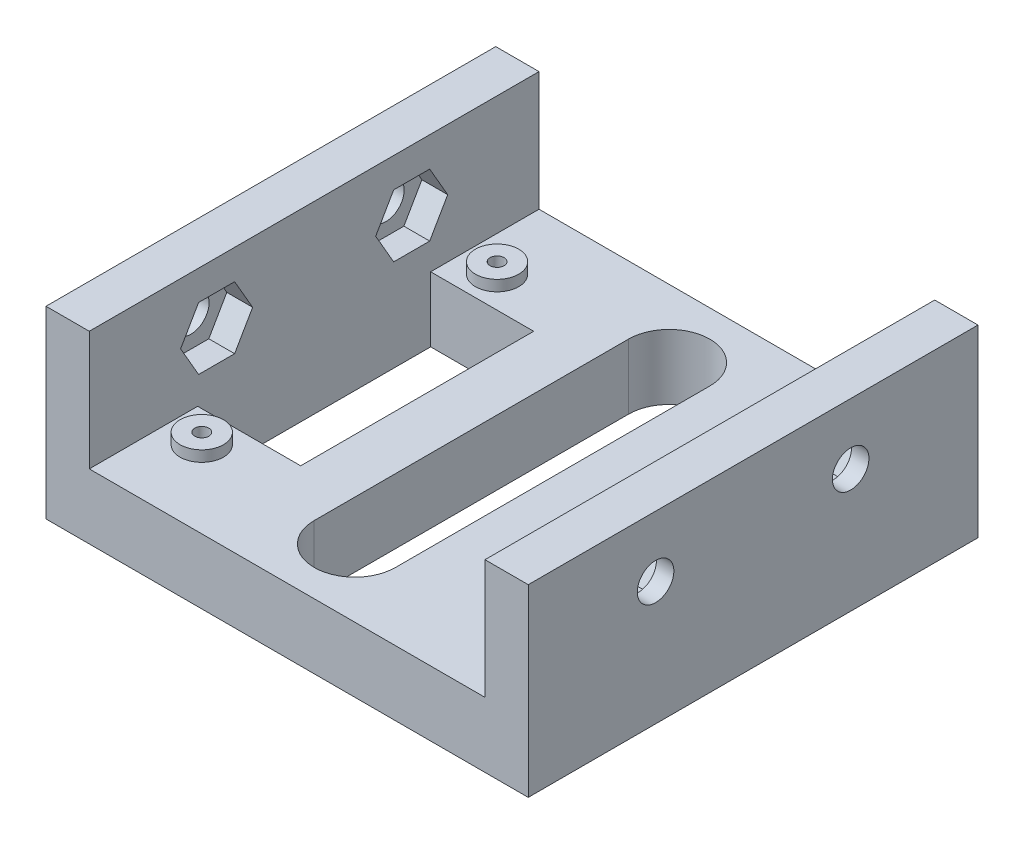
from build123d import *

# Parameters (mm, degrees)
SKETCH1_W                   = 89
SKETCH1_H                   = 83
SKETCH1_R                   = 1.3
MAIN_BODY_DEPTH             = 14
SKETCH2_W                   = 73.025
SKETCH2_H                   = 83
SKETCH2_R                   = 4
SCREW_RISER_DEPTH           = 2
SKETCH4_W                   = 7.9875
SKETCH4_H                   = 83
TOPPER_SUPPORT_DEPTH        = 20
MOUNT_START                 = -44.5
MOUNT_NUTS_DEPTH            = 41.275
F_9_32_MOUNT_HOLES_REACH    = 9.988
SKETCH5_R                   = 3.3734375
SKETCH8_W                   = 19.0125
SKETCH8_H                   = 43
MIDDLE_CUT_DEPTH            = 14
SKETCH9_R                   = 3.3734375
MOUNT_NUTS_P2_DEPTH         = 4.7625
SKETCH9_3_R                 = 3.3734375
F_9_32_MOUNT_HOLES_P2_DEPTH = 7.9875


with BuildPart() as part:
    # Sketch1 → Main Body (new body)
    with BuildSketch(Plane(origin=(0, 0, 0), x_dir=(1, 0, 0), z_dir=(0, 1, 0))):
        with Locations((0, 41.5)):
            Rectangle(SKETCH1_W, SKETCH1_H)
        with Locations((-30, 14.25)):
            Circle(SKETCH1_R, mode=Mode.SUBTRACT)
        with Locations((30, 14.25)):
            Circle(SKETCH1_R, mode=Mode.SUBTRACT)
        with BuildLine():
            Line((-7.5, 12.5), (-7.5, 70.5))
            ThreePointArc((-7.5, 70.5), (0, 78), (7.5, 70.5))
            Line((7.5, 70.5), (7.5, 12.5))
            ThreePointArc((7.5, 12.5), (0, 5), (-7.5, 12.5))
        make_face(mode=Mode.SUBTRACT)
        with Locations((-30, 68.75)):
            Circle(SKETCH1_R, mode=Mode.SUBTRACT)
        with Locations((30, 68.75)):
            Circle(SKETCH1_R, mode=Mode.SUBTRACT)
    extrude(amount=MAIN_BODY_DEPTH)

    # Sketch2 → Screw Riser (cut)
    with BuildSketch(Plane(origin=(0, 14, 0), x_dir=(1, 0, 0), z_dir=(0, 1, 0))):
        with Locations((0, 41.5)):
            Rectangle(SKETCH2_W, SKETCH2_H)
        with Locations((-30, 14.25)):
            Circle(SKETCH2_R, mode=Mode.SUBTRACT)
        with Locations((30, 14.25)):
            Circle(SKETCH2_R, mode=Mode.SUBTRACT)
        with Locations((-30, 68.75)):
            Circle(SKETCH2_R, mode=Mode.SUBTRACT)
        with Locations((30, 68.75)):
            Circle(SKETCH2_R, mode=Mode.SUBTRACT)
    extrude(amount=-SCREW_RISER_DEPTH, mode=Mode.SUBTRACT)

    # Sketch4 → Topper Support (add)
    with BuildSketch(Plane(origin=(0, 14, 0), x_dir=(1, 0, 0), z_dir=(0, 1, 0))):
        with Locations((-40.50625, 41.5)):
            Rectangle(SKETCH4_W, SKETCH4_H)
        with Locations((40.50625, 41.5)):
            Rectangle(SKETCH4_W, SKETCH4_H)
    extrude(amount=TOPPER_SUPPORT_DEPTH)

    # Sketch6 → Mount Nuts (cut)
    with BuildSketch(Plane.ZY.offset(44.5).offset(MOUNT_START)):
        Polygon((-52.855059246, 22.7546875), (-56.177529623, 28.509375), (-62.822470377, 28.509375), (-66.144940754, 22.7546875), (-62.822470377, 17), (-56.177529623, 17), align=None)
        Polygon((-16.855059246, 22.7546875), (-20.177529623, 28.509375), (-26.822470377, 28.509375), (-30.144940754, 22.7546875), (-26.822470377, 17), (-20.177529623, 17), align=None)
    extrude(amount=MOUNT_NUTS_DEPTH, mode=Mode.SUBTRACT)

    # Sketch5 → 9_32 Mount Holes (cut, up to next)
    with BuildSketch(Plane.ZY.offset(36.5125), mode=Mode.PRIVATE) as f_9_32_mount_holes_sk1:
        with Locations((-59.5, 22.7546875)):
            Circle(SKETCH5_R)
    f_9_32_mount_holes_tool1 = extrude(f_9_32_mount_holes_sk1.sketch, amount=F_9_32_MOUNT_HOLES_REACH, mode=Mode.PRIVATE) & part.part
    add(f_9_32_mount_holes_tool1.solids().sort_by_distance((-36.5125, 22.754688, -59.5))[0], mode=Mode.SUBTRACT)
    # Sketch5 → 9_32 Mount Holes (cut, up to next)
    with BuildSketch(Plane.ZY.offset(36.5125), mode=Mode.PRIVATE) as f_9_32_mount_holes_sk2:
        with Locations((-23.5, 22.7546875)):
            Circle(SKETCH5_R)
    f_9_32_mount_holes_tool2 = extrude(f_9_32_mount_holes_sk2.sketch, amount=F_9_32_MOUNT_HOLES_REACH, mode=Mode.PRIVATE) & part.part
    add(f_9_32_mount_holes_tool2.solids().sort_by_distance((-36.5125, 22.754688, -23.5))[0], mode=Mode.SUBTRACT)

    # Sketch8 → Middle Cut (cut)
    with BuildSketch(Plane(origin=(0, 14, 0), x_dir=(1, 0, 0), z_dir=(0, 1, 0))):
        with Locations((-27.00625, 41.5)):
            Rectangle(SKETCH8_W, SKETCH8_H)
        with Locations((27.00625, 41.5)):
            Rectangle(SKETCH8_W, SKETCH8_H)
    extrude(amount=-MIDDLE_CUT_DEPTH, mode=Mode.SUBTRACT)

    # Sketch9 → Mount Nuts p2 (cut)
    with BuildSketch(Plane.ZY.offset(-36.5125)):
        Polygon((-56.177529623, 17), (-62.822470377, 17), (-66.144940754, 22.7546875), (-62.822470377, 28.509375), (-56.177529623, 28.509375), (-52.855059246, 22.7546875), align=None)
        with Locations((-59.5, 22.7546875)):
            Circle(SKETCH9_R, mode=Mode.SUBTRACT)
        with Locations((-59.5, 22.7546875)):
            Circle(SKETCH9_R)
        Polygon((-20.177529623, 17), (-26.822470377, 17), (-30.144940754, 22.7546875), (-26.822470377, 28.509375), (-20.177529623, 28.509375), (-16.855059246, 22.7546875), align=None)
        with Locations((-23.5, 22.7546875)):
            Circle(SKETCH9_R, mode=Mode.SUBTRACT)
        with Locations((-23.5, 22.7546875)):
            Circle(SKETCH9_R)
    extrude(amount=-MOUNT_NUTS_P2_DEPTH, mode=Mode.SUBTRACT)

    # Sketch9_3 → 9_32 Mount Holes p2 (cut)
    with BuildSketch(Plane.ZY.offset(-36.5125)):
        with Locations((-59.5, 22.7546875)):
            Circle(SKETCH9_3_R)
        with Locations((-23.5, 22.7546875)):
            Circle(SKETCH9_3_R)
    extrude(amount=-F_9_32_MOUNT_HOLES_P2_DEPTH, mode=Mode.SUBTRACT)


solid = part.part
